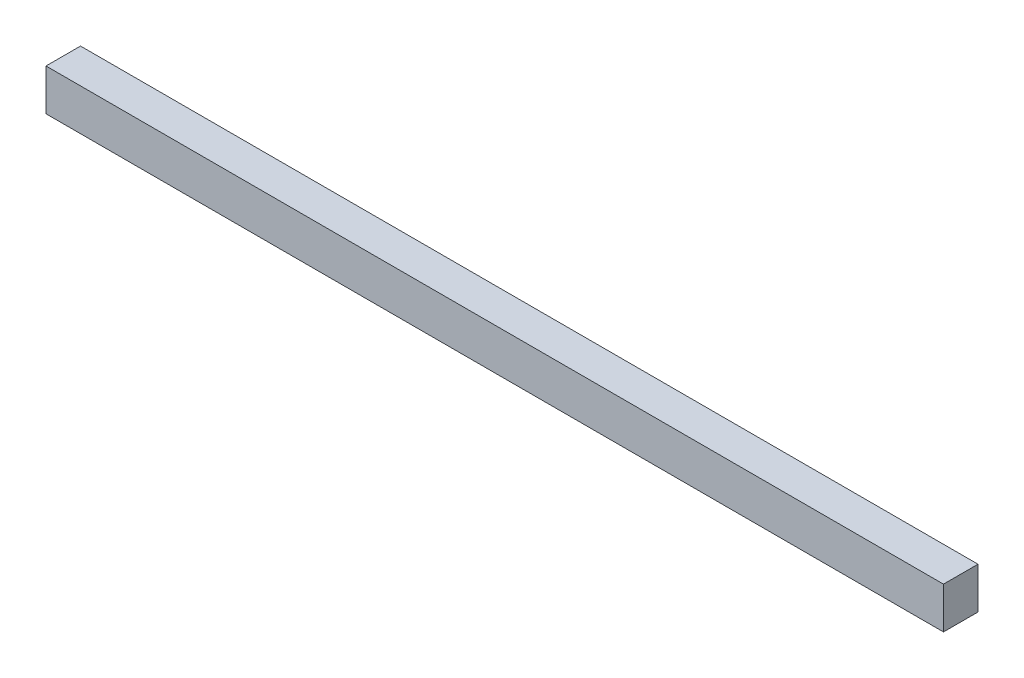
from build123d import *

# Parameters (mm, degrees)
SKETCH1_W           = 33.02
SKETCH1_H           = 1.524
BOSS_EXTRUDE1_DEPTH = 1.27


with BuildPart() as part:
    # Sketch1 → Boss-Extrude1 (new body)
    with BuildSketch(Plane.XY):
        with Locations((16.51, 0.762)):
            Rectangle(SKETCH1_W, SKETCH1_H)
    extrude(amount=BOSS_EXTRUDE1_DEPTH)


solid = part.part
